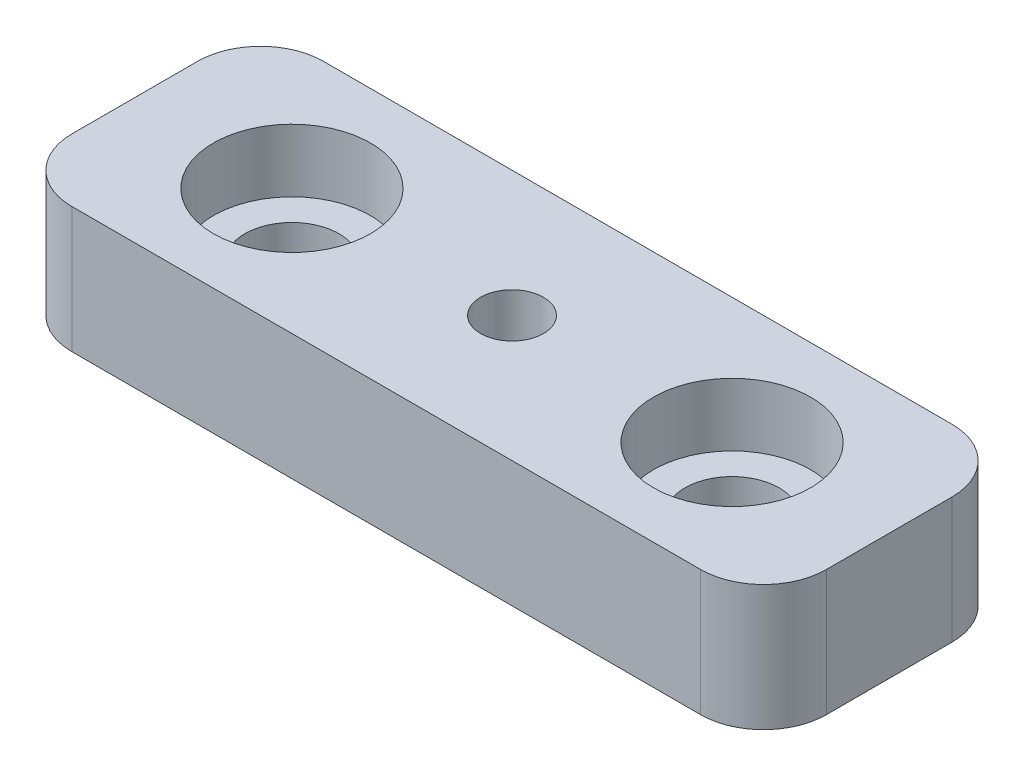
from build123d import *

# Parameters (mm, degrees)
BOSS_EXTRUDE1_DEPTH = 4
CUT_EXTRUDE1_REACH  = 15.266
SKETCH1_3_R         = 1
SKETCH1_3_R_2       = 1.5
SKETCH1_4_R         = 2.5
CUT_EXTRUDE2_DEPTH  = 2
SKETCH2_R           = 2.5
CUT_EXTRUDE3_DEPTH  = 2


with BuildPart() as part:
    # Sketch1 → Boss-Extrude1 (new body)
    with BuildSketch(Plane(origin=(0, 0, 0), x_dir=(1, 0, 0), z_dir=(0, 1, 0))):
        with BuildLine():
            Line((0, 4), (10, 4))
            ThreePointArc((10, 4), (11.414213562, 3.414213562), (12, 2))
            Line((12, 2), (12, -2))
            ThreePointArc((12, -2), (11.414213562, -3.414213562), (10, -4))
            Line((10, -4), (0, -4))
            Line((0, -4), (-10, -4))
            ThreePointArc((-10, -4), (-11.414213562, -3.414213562), (-12, -2))
            Line((-12, -2), (-12, 2))
            ThreePointArc((-12, 2), (-11.414213562, 3.414213562), (-10, 4))
            Line((-10, 4), (0, 4))
        make_face()
    extrude(amount=BOSS_EXTRUDE1_DEPTH)

    # Sketch1_3 → Cut-Extrude1 (cut, up to next)
    with BuildSketch(Plane(origin=(0, 0, 0), x_dir=(1, 0, 0), z_dir=(0, 1, 0)), mode=Mode.PRIVATE) as cut_extrude1_sk1:
        Circle(SKETCH1_3_R)
    cut_extrude1_tool1 = extrude(cut_extrude1_sk1.sketch, amount=CUT_EXTRUDE1_REACH, mode=Mode.PRIVATE) & part.part
    # Sketch1_3 → Cut-Extrude1 (cut, up to next)
    with BuildSketch(Plane(origin=(0, 0, 0), x_dir=(1, 0, 0), z_dir=(0, 1, 0)), mode=Mode.PRIVATE) as cut_extrude1_sk2:
        with Locations((-7, 0)):
            Circle(SKETCH1_3_R_2)
    cut_extrude1_tool2 = extrude(cut_extrude1_sk2.sketch, amount=CUT_EXTRUDE1_REACH, mode=Mode.PRIVATE) & part.part
    # Sketch1_3 → Cut-Extrude1 (cut, up to next)
    with BuildSketch(Plane(origin=(0, 0, 0), x_dir=(1, 0, 0), z_dir=(0, 1, 0)), mode=Mode.PRIVATE) as cut_extrude1_sk3:
        with Locations((7, 0)):
            Circle(SKETCH1_3_R_2)
    cut_extrude1_tool3 = extrude(cut_extrude1_sk3.sketch, amount=CUT_EXTRUDE1_REACH, mode=Mode.PRIVATE) & part.part
    add(cut_extrude1_tool1.solids().sort_by_distance((0, 0, 0))[0], mode=Mode.SUBTRACT)
    add(cut_extrude1_tool2.solids().sort_by_distance((-7, 0, 0))[0], mode=Mode.SUBTRACT)
    add(cut_extrude1_tool3.solids().sort_by_distance((7, 0, 0))[0], mode=Mode.SUBTRACT)

    # Sketch1_4 → Cut-Extrude2 (cut)
    with BuildSketch(Plane(origin=(0, 0, 0), x_dir=(1, 0, 0), z_dir=(0, 1, 0))):
        Circle(SKETCH1_4_R)
    extrude(amount=CUT_EXTRUDE2_DEPTH, mode=Mode.SUBTRACT)

    # Sketch2 → Cut-Extrude3 (cut)
    with BuildSketch(Plane(origin=(0, 4, 0), x_dir=(1, 0, 0), z_dir=(0, 1, 0))):
        with Locations((-7, 0)):
            Circle(SKETCH2_R)
        with Locations((7, 0)):
            Circle(SKETCH2_R)
    extrude(amount=-CUT_EXTRUDE3_DEPTH, mode=Mode.SUBTRACT)


solid = part.part
